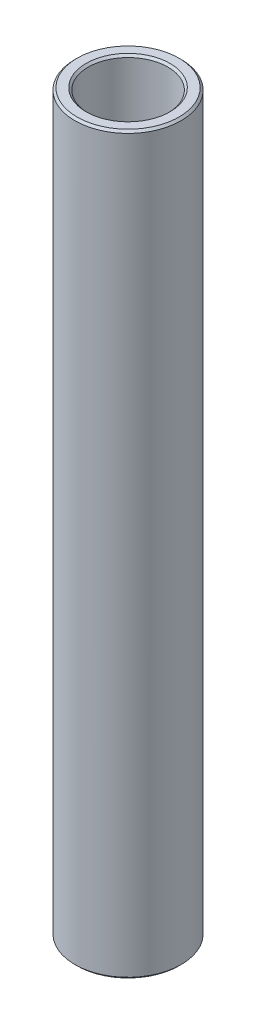
from build123d import *

# Parameters (mm, degrees)
SKETCH1_W     = 1.5875
SKETCH1_H     = 87.864991064
CHAMFER1_SIZE = 0.254


with BuildPart() as part:
    # Sketch1 → Revolve1 (revolve)
    with BuildSketch(Plane.XY):
        with Locations((5.55625, 175.694885462)):
            Rectangle(SKETCH1_W, SKETCH1_H)
    revolve(axis=Axis((0, 122.23738993, 0), (0, 1, 0)))

    # Chamfer1
    chamfer1_edges = [part.edges().sort_by_distance(p)[0] for p in [
        (-6.35, 131.76238993, 0),
        (-6.35, 219.627380994, 0),
        (-4.7625, 219.627380994, 0),
        (-4.7625, 131.76238993, 0),
    ]]
    chamfer(chamfer1_edges, length=CHAMFER1_SIZE)


solid = part.part
